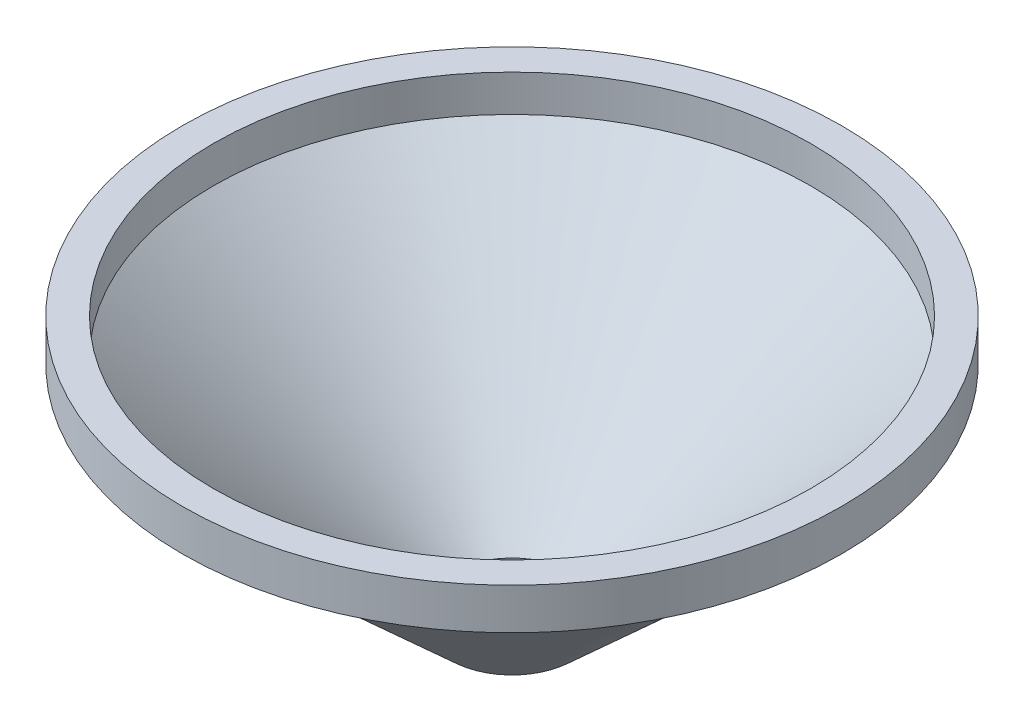
from build123d import *

# Parameters (mm, degrees)
SKETCH2_W          = 1
SKETCH2_H          = 2
SKETCH3_R          = 3
CUT_EXTRUDE1_DEPTH = 16


with BuildPart() as part:
    # Sketch1 → Revolve-Thin1 (revolve)
    with BuildSketch(Plane.XY):
        with BuildLine():
            Line((15, 0), (15, -2))
            Line((15, -2), (1.349281284, -14.47629266))
            ThreePointArc((1.349281284, -14.47629266), (0.723676268, -14.864481874), (0, -15))
            Line((0, -15), (0, -14.5))
            ThreePointArc((0, -14.5), (0.542757201, -14.398361406), (1.011960963, -14.107219495))
            Line((1.011960963, -14.107219495), (14.5, -1.779610529))
            Line((14.5, -1.779610529), (14.5, 0))
            Line((14.5, 0), (15, 0))
        make_face()
    revolve(axis=Axis((0, 0, 0), (0, -1, 0)))

    # Sketch2 → Revolve1 (revolve)
    with BuildSketch(Plane.XY):
        with Locations((-15.5, -1)):
            Rectangle(SKETCH2_W, SKETCH2_H)
    revolve(axis=Axis((0, 0, 0), (0, -1, 0)))

    # Sketch3 → Cut-Extrude1 (cut, through all)
    with BuildSketch(Plane(origin=(0, 0, 0), x_dir=(-1, 0, 0), z_dir=(0, 1, 0))):
        Circle(SKETCH3_R)
    extrude(amount=-CUT_EXTRUDE1_DEPTH, mode=Mode.SUBTRACT)


solid = part.part
